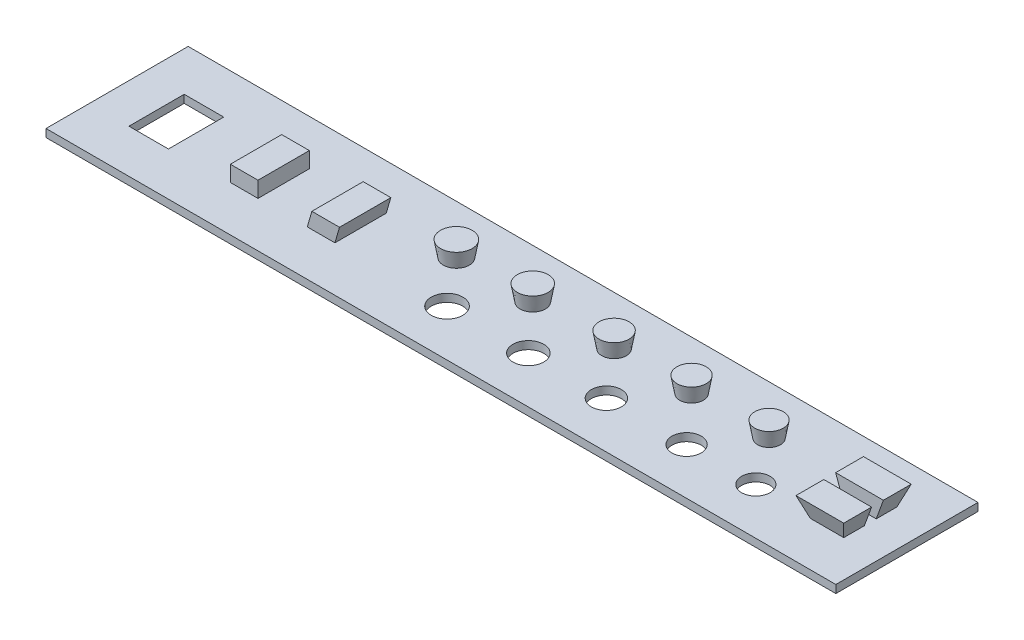
from build123d import *

# Parameters (mm, degrees)
SKETCH1_W           = 100
SKETCH1_H           = 18
SKETCH1_W_2         = 5
SKETCH1_H_2         = 7
SKETCH1_W_3         = 3.5
SKETCH1_H_3         = 6
SKETCH1_H_4         = 6.5
BOSS_EXTRUDE1_DEPTH = 1
SKETCH2_W           = 3.5
SKETCH2_H           = 6
BOSS_EXTRUDE2_DEPTH = 3.5
BOSS_EXTRUDE2_TAPER = -20
SKETCH3_W           = 6.04779164
SKETCH3_H           = 1.5
CUT_EXTRUDE1_DEPTH  = 2.5
SKETCH4_W           = 3.5
SKETCH4_H           = 6.5
BOSS_EXTRUDE3_DEPTH = 3
BOSS_EXTRUDE4_DEPTH = 6.5
SKETCH10_R          = 1.8
SKETCH10_R_2        = 1.85
SKETCH10_R_3        = 1.9
SKETCH10_R_4        = 1.95
SKETCH10_R_5        = 2
CUT_EXTRUDE2_DEPTH  = 2
SKETCH10_3_R        = 1.45
SKETCH10_3_R_2      = 1.5
SKETCH10_3_R_3      = 1.55
SKETCH10_3_R_4      = 1.6
SKETCH10_3_R_5      = 1.65
BOSS_EXTRUDE5_DEPTH = 2
BOSS_EXTRUDE5_TAPER = -10


with BuildPart() as part:
    # Sketch1 → Boss-Extrude1 (new body)
    with BuildSketch(Plane(origin=(0, 0, 0), x_dir=(1, 0, 0), z_dir=(0, 1, 0))):
        with Locations((50, 9)):
            Rectangle(SKETCH1_W, SKETCH1_H)
        with Locations((7.5, 9)):
            Rectangle(SKETCH1_W_2, SKETCH1_H_2, mode=Mode.SUBTRACT)
        with Locations((93.25, 9)):
            Rectangle(SKETCH1_W_3, SKETCH1_H_3, mode=Mode.SUBTRACT)
        with Locations((19.340066027, 9)):
            Rectangle(SKETCH1_W_3, SKETCH1_H_4, mode=Mode.SUBTRACT)
    extrude(amount=BOSS_EXTRUDE1_DEPTH)

    # Sketch2 → Boss-Extrude2 (add)
    with BuildSketch(Plane.XZ):
        with Locations((93.25, -9)):
            Rectangle(SKETCH2_W, SKETCH2_H)
    extrude(amount=-BOSS_EXTRUDE2_DEPTH, taper=BOSS_EXTRUDE2_TAPER)

    # Sketch3 → Cut-Extrude1 (cut)
    with BuildSketch(Plane(origin=(0, 3.5, 0), x_dir=(1, 0, 0), z_dir=(0, 1, 0))):
        with Locations((93.25, 9)):
            Rectangle(SKETCH3_W, SKETCH3_H)
    extrude(amount=-CUT_EXTRUDE1_DEPTH, mode=Mode.SUBTRACT)

    # Sketch4 → Boss-Extrude3 (add)
    with BuildSketch(Plane.XZ):
        with Locations((19.340066027, -9)):
            Rectangle(SKETCH4_W, SKETCH4_H)
    extrude(amount=-BOSS_EXTRUDE3_DEPTH)

    # Sketch9 → Boss-Extrude4 (add)
    with BuildSketch(Plane(origin=(0, 0, -12.25), x_dir=(-1, 0, 0), z_dir=(0, 0, -1))):
        Polygon((-31.411175368, 3), (-27.911175368, 3), (-27.038919355, 0), (-30.538919355, 0), align=None)
    extrude(amount=-BOSS_EXTRUDE4_DEPTH)

    # Sketch10 → Cut-Extrude2 (cut, through all)
    with BuildSketch(Plane(origin=(0, 1, 0), x_dir=(1, 0, 0), z_dir=(0, 1, 0))):
        with Locations((83.971192641, 5.901209197)):
            Circle(SKETCH10_R)
        with Locations((75.205441642, 5.901209197)):
            Circle(SKETCH10_R_2)
        with Locations((65.048301596, 5.901209197)):
            Circle(SKETCH10_R_3)
        with Locations((55.169439359, 5.901209197)):
            Circle(SKETCH10_R_4)
        with Locations((44.873160409, 5.901209197)):
            Circle(SKETCH10_R_5)
    extrude(amount=-CUT_EXTRUDE2_DEPTH, mode=Mode.SUBTRACT)

    # Sketch10_3 → Boss-Extrude5 (add)
    with BuildSketch(Plane(origin=(0, 1, 0), x_dir=(1, 0, 0), z_dir=(0, 1, 0))):
        with Locations((79.727456046, 11.814612648)):
            Circle(SKETCH10_3_R)
        with Locations((69.918163262, 11.814612648)):
            Circle(SKETCH10_3_R_2)
        with Locations((60.108870478, 11.814612648)):
            Circle(SKETCH10_3_R_3)
        with Locations((49.812591527, 11.814612648)):
            Circle(SKETCH10_3_R_4)
        with Locations((40.142437647, 11.814612648)):
            Circle(SKETCH10_3_R_5)
    extrude(amount=BOSS_EXTRUDE5_DEPTH, taper=BOSS_EXTRUDE5_TAPER)


solid = part.part
